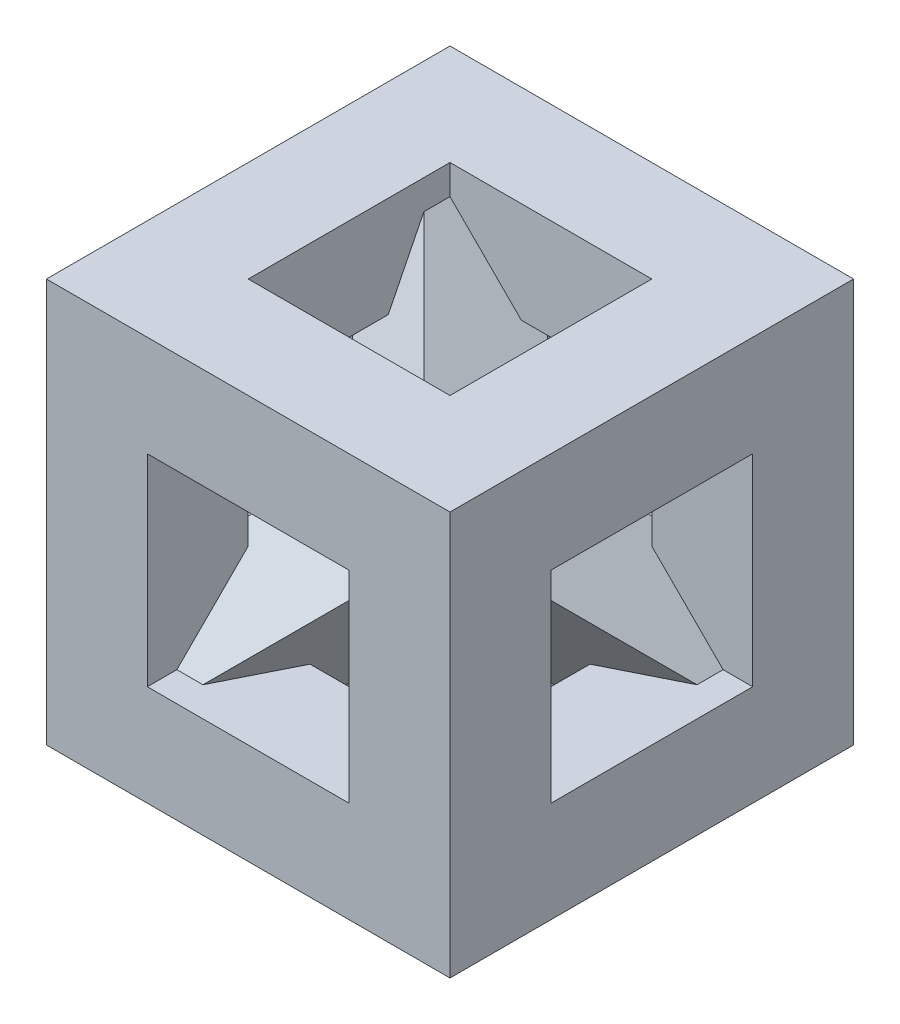
from build123d import *

# Parameters (mm, degrees)
SKETCH1_W           = 10
SKETCH1_H           = 10
BOSS_EXTRUDE1_DEPTH = 10
SKETCH2_W           = 5
SKETCH2_H           = 5
CUT_EXTRUDE1_DEPTH  = 13
SKETCH3_W           = 5
SKETCH3_H           = 5
CUT_EXTRUDE2_DEPTH  = 13
SKETCH4_W           = 5
SKETCH4_H           = 5
CUT_EXTRUDE3_DEPTH  = 13
SKETCH5_W           = 2.5
SKETCH5_H           = 2.5
BOSS_EXTRUDE3_DEPTH = 12
SKETCH7_W           = 2.5
SKETCH7_H           = 2.5
BOSS_EXTRUDE4_DEPTH = 12
SKETCH9_W           = 2.5
SKETCH9_H           = 2.5
BOSS_EXTRUDE5_DEPTH = 12
SKETCH11_W          = 2.5
SKETCH11_H          = 2.5
BOSS_EXTRUDE6_DEPTH = 12


with BuildPart() as part:
    # Sketch1 → Boss-Extrude1 (new body)
    with BuildSketch(Plane.XY):
        Rectangle(SKETCH1_W, SKETCH1_H)
    extrude(amount=BOSS_EXTRUDE1_DEPTH)

    # Sketch2 → Cut-Extrude1 (cut)
    with BuildSketch(Plane.XY.offset(10)):
        Rectangle(SKETCH2_W, SKETCH2_H)
    extrude(amount=-CUT_EXTRUDE1_DEPTH, mode=Mode.SUBTRACT)

    # Sketch3 → Cut-Extrude2 (cut)
    with BuildSketch(Plane(origin=(5, 0, 0), x_dir=(0, 0, -1), z_dir=(1, 0, 0))):
        with Locations((-5, 0)):
            Rectangle(SKETCH3_W, SKETCH3_H)
    extrude(amount=-CUT_EXTRUDE2_DEPTH, mode=Mode.SUBTRACT)

    # Sketch4 → Cut-Extrude3 (cut)
    with BuildSketch(Plane(origin=(0, 5, 0), x_dir=(1, 0, 0), z_dir=(0, 1, 0))):
        with Locations((0, -5)):
            Rectangle(SKETCH4_W, SKETCH4_H)
    extrude(amount=-CUT_EXTRUDE3_DEPTH, mode=Mode.SUBTRACT)

    # Sketch5 → Boss-Extrude3 (add)
    with BuildSketch(Plane(origin=(-5, -5, 5), x_dir=(-0.816496581, 0.40824829, -0.40824829), z_dir=(-0.577350269, -0.577350269, 0.577350269))):
        with Locations((-2.041241452, -3.535533906)):
            Rectangle(SKETCH5_W, SKETCH5_H)
    extrude(amount=-BOSS_EXTRUDE3_DEPTH)

    # Sketch7 → Boss-Extrude4 (add)
    with BuildSketch(Plane(origin=(-1.666666667, 1.666666667, -1.666666667), x_dir=(-0.40824829, 0.40824829, 0.816496581), z_dir=(-0.577350269, 0.577350269, -0.577350269))):
        with Locations((4.082482905, 0)):
            Rectangle(SKETCH7_W, SKETCH7_H)
    extrude(amount=-BOSS_EXTRUDE4_DEPTH)

    # Sketch9 → Boss-Extrude5 (add)
    with BuildSketch(Plane(origin=(-5, 5, 5), x_dir=(0.40824829, -0.40824829, 0.816496581), z_dir=(-0.577350269, 0.577350269, 0.577350269))):
        with Locations((4.082482905, 0)):
            Rectangle(SKETCH9_W, SKETCH9_H)
    extrude(amount=-BOSS_EXTRUDE5_DEPTH)

    # Sketch11 → Boss-Extrude6 (add)
    with BuildSketch(Plane(origin=(5, 5, 5), x_dir=(0.816496581, -0.40824829, -0.40824829), z_dir=(0.577350269, 0.577350269, 0.577350269))):
        with Locations((-2.041241452, -3.535533906)):
            Rectangle(SKETCH11_W, SKETCH11_H)
    extrude(amount=-BOSS_EXTRUDE6_DEPTH)


solid = part.part
